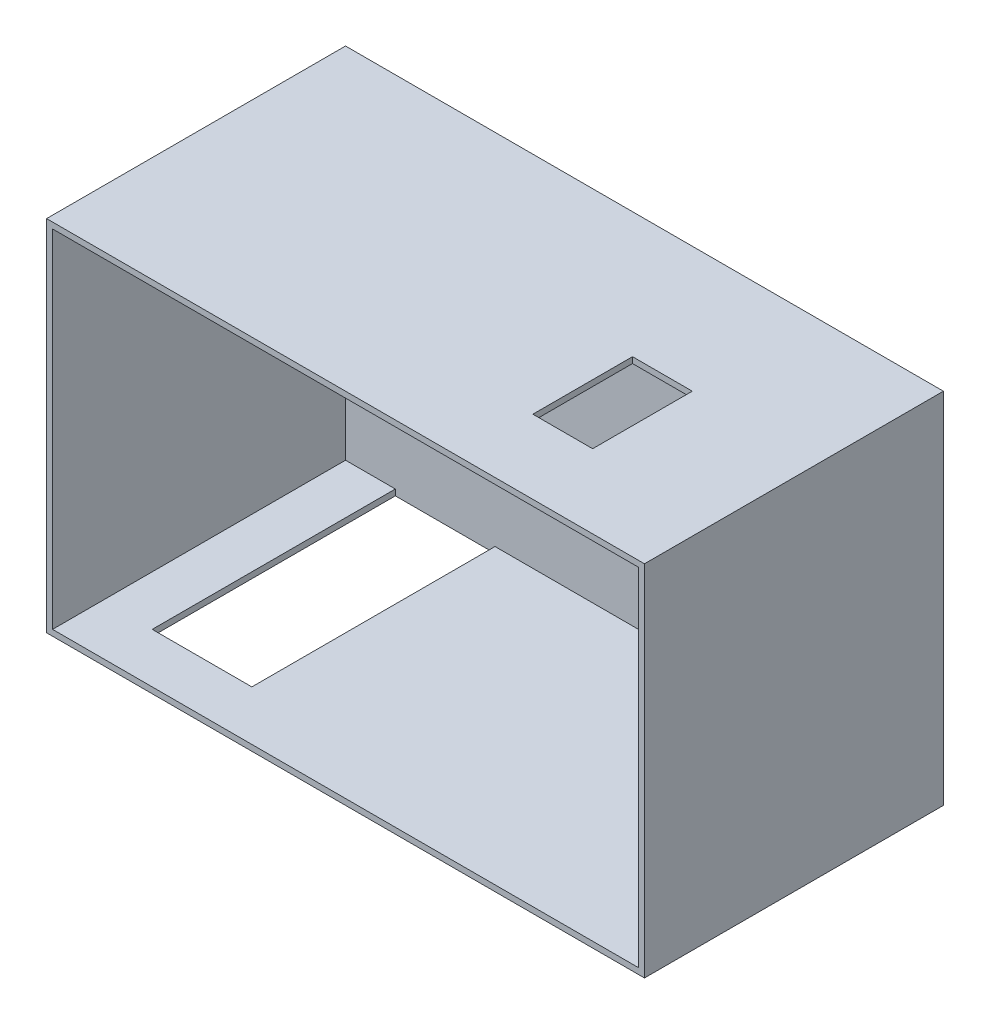
from build123d import *

# Parameters (mm, degrees)
ESQUISSE1_W             = 300
ESQUISSE1_H             = 180
BOSS_EXTRU_1_DEPTH      = 150
COQUE1_T                = -3
ENL_V_MAT_EXTRU_1_REACH = 5
ESQUISSE2_W             = 50
ESQUISSE2_H             = 122
ENL_V_MAT_EXTRU_2_REACH = 5
ESQUISSE3_W             = 30
ESQUISSE3_H             = 50


with BuildPart() as part:
    # Esquisse1 → Boss.-Extru.1 (new body)
    with BuildSketch(Plane.XY):
        with Locations((-150, 90)):
            Rectangle(ESQUISSE1_W, ESQUISSE1_H)
    extrude(amount=BOSS_EXTRU_1_DEPTH)

    # Coque1
    coque1_openings = [part.faces().sort_by_distance(p)[0] for p in [
        (-150, 90, 150),
    ]]
    offset(amount=COQUE1_T, openings=coque1_openings, kind=Kind.INTERSECTION)

    # Esquisse2 → Enlèv. mat.-Extru.1 (cut, up to next)
    with BuildSketch(Plane(origin=(0, 3, 0), x_dir=(1, 0, 0), z_dir=(0, 1, 0)), mode=Mode.PRIVATE) as enl_v_mat_extru_1_sk1:
        with Locations((-247, -64)):
            Rectangle(ESQUISSE2_W, ESQUISSE2_H)
    enl_v_mat_extru_1_tool1 = extrude(enl_v_mat_extru_1_sk1.sketch, amount=-ENL_V_MAT_EXTRU_1_REACH, mode=Mode.PRIVATE) & part.part
    add(enl_v_mat_extru_1_tool1.solids().sort_by_distance((-247, 3, 64))[0], mode=Mode.SUBTRACT)

    # Esquisse3 → Enlèv. mat.-Extru.2 (cut, up to next)
    with BuildSketch(Plane.XZ.offset(-177), mode=Mode.PRIVATE) as enl_v_mat_extru_2_sk1:
        with Locations((-78, 88)):
            Rectangle(ESQUISSE3_W, ESQUISSE3_H)
    enl_v_mat_extru_2_tool1 = extrude(enl_v_mat_extru_2_sk1.sketch, amount=-ENL_V_MAT_EXTRU_2_REACH, mode=Mode.PRIVATE) & part.part
    add(enl_v_mat_extru_2_tool1.solids().sort_by_distance((-78, 177, 88))[0], mode=Mode.SUBTRACT)


solid = part.part
